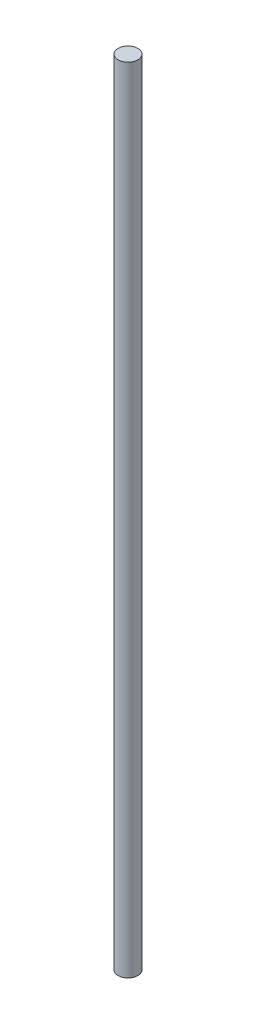
from build123d import *

# Parameters (mm, degrees)
SKETCH1_R           = 6.35
BOSS_EXTRUDE1_DEPTH = 508


with BuildPart() as part:
    # Sketch1 → Boss-Extrude1 (new body)
    with BuildSketch(Plane(origin=(0, 0, 0), x_dir=(1, 0, 0), z_dir=(0, 1, 0))):
        Circle(SKETCH1_R)
    extrude(amount=BOSS_EXTRUDE1_DEPTH)


solid = part.part
